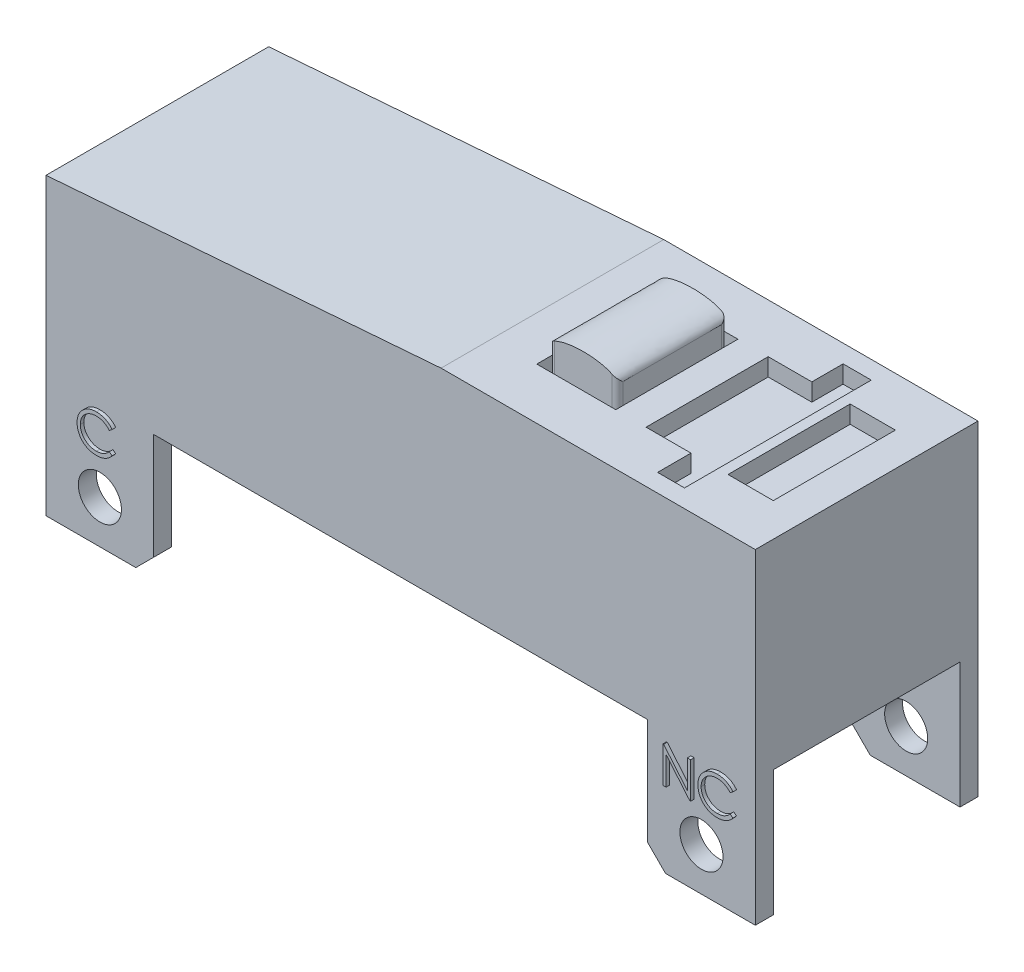
from build123d import *

# Parameters (mm, degrees)
SKETCH3_R               = 0.6
BOSS_EXTRUDE1_DEPTH     = 6.2
SHELL1_T                = -0.5
SKETCH5_W               = 5.2
SKETCH5_H               = 3.5
CUT_EXTRUDE1_DEPTH      = 1
CUT_EXTRUDE1_DEPTH_BACK = 20.75
SKETCH6_W               = 1.26
SKETCH6_H               = 3.4
CUT_EXTRUDE2_DEPTH      = 0.49
SKETCH7_W               = 2.2
SKETCH7_H               = 3.4
CUT_EXTRUDE3_DEPTH      = 0.49
BOSS_EXTRUDE2_DEPTH     = 1.24
CUT_EXTRUDE4_DEPTH      = 2.63
CUT_EXTRUDE4_DEPTH_BACK = 5.57
BOSS_EXTRUDE3_DEPTH     = 0.1


with BuildPart() as part:
    # Sketch3 → Boss-Extrude1 (new body)
    with BuildSketch(Plane.XY):
        Polygon((11.659703504, 6.419407008), (5.659703504, 6.419407008), (2.909703504, 6.419407008), (-8.090296496, 5.569407008), (-8.090296496, -2.640592992), (-5.590296496, -2.640592992), (-5.090296496, -2.140592992), (-5.090296496, 0.819407008), (8.659703504, 0.819407008), (8.659703504, -2.140592992), (9.159703504, -2.640592992), (11.659703504, -2.640592992), align=None)
        with Locations((-6.590296496, -1.440592992)):
            Circle(SKETCH3_R, mode=Mode.SUBTRACT)
        with Locations((10.159703504, -1.440592992)):
            Circle(SKETCH3_R, mode=Mode.SUBTRACT)
    extrude(amount=BOSS_EXTRUDE1_DEPTH)

    # Shell1
    shell1_openings = [part.faces().sort_by_distance(p)[0] for p in [
        (10.409703504, -2.640592992, 3.1),
        (8.659703504, -0.660592992, 3.1),
        (1.784703504, 0.819407008, 3.1),
        (-5.090296496, -0.660592992, 3.1),
        (-6.840296496, -2.640592992, 3.1),
    ]]
    offset(amount=SHELL1_T, openings=shell1_openings)

    # Sketch5 → Cut-Extrude1 (cut, two sides)
    with BuildSketch(Plane(origin=(11.659703504, 0, 0), x_dir=(0, 0, -1), z_dir=(1, 0, 0))) as cut_extrude1_sk:
        with Locations((-3.1, -0.890592992)):
            Rectangle(SKETCH5_W, SKETCH5_H)
    extrude(amount=CUT_EXTRUDE1_DEPTH, mode=Mode.SUBTRACT)
    extrude(cut_extrude1_sk.sketch, amount=-CUT_EXTRUDE1_DEPTH_BACK, mode=Mode.SUBTRACT)

    # Sketch6 → Cut-Extrude2 (cut)
    with BuildSketch(Plane(origin=(0, 6.419407008, 0), x_dir=(1, 0, 0), z_dir=(0, 1, 0))):
        with Locations((10.099703504, -3.07)):
            Rectangle(SKETCH6_W, SKETCH6_H)
    extrude(amount=-CUT_EXTRUDE2_DEPTH, mode=Mode.SUBTRACT)

    # Sketch7 → Cut-Extrude3 (cut)
    with BuildSketch(Plane(origin=(0, 6.419407008, 0), x_dir=(1, 0, 0), z_dir=(0, 1, 0))):
        Polygon((9.18784127, -0.5), (9.18784127, -5.7), (8.43784127, -5.7), (8.43784127, -4.77), (7.18784127, -4.77), (7.18784127, -1.37), (8.403045117, -1.37), (8.403045117, -0.5), align=None)
        with Locations((5.244810149, -3.07)):
            Rectangle(SKETCH7_W, SKETCH7_H)
    extrude(amount=-CUT_EXTRUDE3_DEPTH, mode=Mode.SUBTRACT)

    # Sketch8 → Boss-Extrude2 (add)
    with BuildSketch(Plane(origin=(0, 5.929407008, 0), x_dir=(1, 0, 0), z_dir=(0, 1, 0))):
        with BuildLine():
            Line((4.444810149, -1.52), (6.044810149, -1.52))
            ThreePointArc((6.044810149, -1.52), (6.150876166, -1.563933983), (6.194810149, -1.67))
            Line((6.194810149, -1.67), (6.194810149, -4.42))
            ThreePointArc((6.194810149, -4.42), (6.150876166, -4.526066017), (6.044810149, -4.57))
            Line((6.044810149, -4.57), (4.444810149, -4.57))
            ThreePointArc((4.444810149, -4.57), (4.338744132, -4.526066017), (4.294810149, -4.42))
            Line((4.294810149, -4.42), (4.294810149, -1.67))
            ThreePointArc((4.294810149, -1.67), (4.338744132, -1.563933983), (4.444810149, -1.52))
        make_face()
    extrude(amount=BOSS_EXTRUDE2_DEPTH)

    # Sketch9 → Cut-Extrude4 (cut, two sides)
    with BuildSketch(Plane.XY.offset(4.57)) as cut_extrude4_sk:
        with BuildLine():
            Line((4.294810149, 7.169407008), (4.294810149, 6.847617942))
            add(Edge.make_bspline(
                [(4.444810149, 7.021163032), (4.294810149, 6.941828134), (4.294810149, 6.847617942)],
                knots=[5.703153856, 5.703153856, 5.703153856, 6.283185307, 6.283185307, 6.283185307], degree=2, weights=[0.863566286, 0.891846399, 1]))
            Line((4.444810149, 7.021163032), (4.444810149, 7.169407008))
            Line((4.444810149, 7.169407008), (4.294810149, 7.169407008))
        make_face()
        with BuildLine():
            Line((4.444810149, 7.169407008), (4.444810149, 7.021163032))
            add(Edge.make_bspline(
                [(5.244810149, 7.169407008), (4.725097851, 7.169407008), (4.444810149, 7.021163032)],
                knots=[4.71238898, 4.71238898, 4.71238898, 5.703153856, 5.703153856, 5.703153856], degree=2, weights=[1, 0.815260382, 0.863566286]))
            Line((5.244810172, 7.169407008), (4.444810149, 7.169407008))
        make_face()
        with BuildLine():
            Line((6.044810149, 7.169407008), (5.244810172, 7.169407008))
            add(Edge.make_bspline(
                [(6.044810149, 7.021163032), (5.764522447, 7.169407008), (5.244810149, 7.169407008)],
                knots=[3.721624105, 3.721624105, 3.721624105, 4.71238898, 4.71238898, 4.71238898], degree=2, weights=[0.863566286, 0.815260382, 1]))
            Line((6.044810149, 7.021163032), (6.044810149, 7.169407008))
        make_face()
        with BuildLine():
            Line((6.194810149, 7.169407008), (6.044810149, 7.169407008))
            Line((6.044810149, 7.169407008), (6.044810149, 7.021163032))
            add(Edge.make_bspline(
                [(6.194810149, 6.847617942), (6.194810149, 6.941828134), (6.044810149, 7.021163032)],
                knots=[3.141592654, 3.141592654, 3.141592654, 3.721624105, 3.721624105, 3.721624105], degree=2, weights=[1, 0.891846399, 0.863566286]))
            Line((6.194810149, 6.847617942), (6.194810149, 7.169407008))
        make_face()
    extrude(amount=CUT_EXTRUDE4_DEPTH, mode=Mode.SUBTRACT)
    extrude(cut_extrude4_sk.sketch, amount=-CUT_EXTRUDE4_DEPTH_BACK, mode=Mode.SUBTRACT)

    # Sketch11 → Boss-Extrude3 (add)
    with BuildSketch(Plane.XY.offset(6.2)):
        Polygon((9.18687242, -0.45139452), (9.18687242, 0.54860548), (9.205702548, 0.54860548), (9.8663596, -0.238453815), (9.8663596, 0.54860548), (9.956103189, 0.54860548), (9.956103189, -0.45139452), (9.935670497, -0.45139452), (9.27661601, 0.333861891), (9.27661601, -0.45139452), align=None)
        with BuildLine():
            Line((11.135590369, 0.365111891), (11.057064728, 0.305015737))
            add(Edge.make_bspline(
                [(11.057064728, 0.305015737), (11.051463045, 0.311691728), (11.040335203, 0.324953704), (11.022432574, 0.343576431), (11.003774962, 0.361023649), (10.984369499, 0.377378471), (10.963866893, 0.392068976), (10.942763808, 0.40586072), (10.920707223, 0.41822293), (10.890206728, 0.433212355), (10.850307343, 0.448854114), (10.800080246, 0.461969323), (10.747648503, 0.47031823), (10.711877761, 0.47122247), (10.693683317, 0.471682403)],
                knots=[0, 0, 0, 0, 2.6139e-05, 5.1925e-05, 7.7436e-05, 0.000102751, 0.000127994, 0.000153053, 0.000178348, 0.000203791, 0.000254978, 0.00030658, 0.000359276, 0.000413825, 0.000413825, 0.000413825, 0.000413825], degree=3))
            add(Edge.make_bspline(
                [(10.693683317, 0.471682403), (10.683659518, 0.471566986), (10.663704948, 0.471337221), (10.634091099, 0.468306042), (10.605030227, 0.464045697), (10.576541237, 0.457724176), (10.548660391, 0.449731999), (10.521205419, 0.440181881), (10.494573819, 0.428366212), (10.46839718, 0.415306709), (10.443317405, 0.400556011), (10.419587392, 0.384466482), (10.397293687, 0.367218168), (10.376418655, 0.348746424), (10.356940955, 0.329134435), (10.339001723, 0.308173195), (10.322663035, 0.285929716), (10.307601028, 0.262697314), (10.294111675, 0.238543659), (10.282817424, 0.213379354), (10.27281596, 0.187635324), (10.264901891, 0.161020707), (10.258637743, 0.133722774), (10.254315554, 0.105668263), (10.251318848, 0.076915783), (10.251090226, 0.057427408), (10.250974984, 0.047603878)],
                knots=[0, 0, 0, 0, 3.0059e-05, 5.9839e-05, 8.9217e-05, 0.000118137, 0.000147304, 0.000176195, 0.000205261, 0.000234645, 0.000263917, 0.000292475, 0.000320603, 0.000348418, 0.00037604, 0.00040346, 0.000431105, 0.000458776, 0.000486483, 0.000514004, 0.000541459, 0.000569281, 0.000597223, 0.000625414, 0.000654396, 0.000683854, 0.000683854, 0.000683854, 0.000683854], degree=3))
            add(Edge.make_bspline(
                [(10.250974984, 0.047603878), (10.251335504, 0.032823501), (10.252043337, 0.003804191), (10.258342861, -0.038701698), (10.267915744, -0.079421891), (10.282263051, -0.118101845), (10.299954209, -0.155218519), (10.322308669, -0.190143906), (10.348199108, -0.223405781), (10.3779918, -0.254218052), (10.410679176, -0.282364831), (10.445750008, -0.307150711), (10.483116947, -0.327812106), (10.522367413, -0.345005234), (10.563803445, -0.358221442), (10.607350532, -0.367525477), (10.652913959, -0.373594672), (10.684048073, -0.374175725), (10.699893253, -0.374471443)],
                knots=[0, 0, 0, 0, 4.4316e-05, 8.7009e-05, 0.000128647, 0.000169585, 0.000210529, 0.000251766, 0.000293722, 0.000336791, 0.000380117, 0.000422965, 0.000465381, 0.000507994, 0.000551326, 0.000595608, 0.00064145, 0.00068896, 0.00068896, 0.00068896, 0.00068896], degree=3))
            add(Edge.make_bspline(
                [(10.699893253, -0.374471443), (10.717351165, -0.373988934), (10.75171251, -0.373039242), (10.802103375, -0.364993742), (10.850342165, -0.351948623), (10.896431475, -0.333692074), (10.940241374, -0.309959134), (10.98184042, -0.281188312), (11.021263726, -0.247105931), (11.044969806, -0.22108218), (11.057064728, -0.207804776)],
                knots=[0, 0, 0, 0, 5.2348e-05, 0.000103034, 0.00015265, 0.000202013, 0.000251398, 0.000301797, 0.000353488, 0.000407333, 0.000407333, 0.000407333, 0.000407333], degree=3))
            Line((11.057064728, -0.207804776), (11.135590369, -0.267299968))
            add(Edge.make_bspline(
                [(11.135590369, -0.267299968), (11.129270909, -0.275453812), (11.116662259, -0.291722442), (11.096245682, -0.314657216), (11.074737883, -0.336229798), (11.051979109, -0.356266261), (11.028231168, -0.375167537), (11.003067651, -0.392396632), (10.976819356, -0.408194027), (10.949575219, -0.422658863), (10.921364187, -0.435492362), (10.892220062, -0.446479153), (10.862268469, -0.455943407), (10.831508038, -0.463729674), (10.799874965, -0.469807127), (10.767483401, -0.473869891), (10.734263437, -0.476653295), (10.711851602, -0.476906986), (10.700494215, -0.477035545)],
                knots=[0, 0, 0, 0, 3.0941e-05, 6.1734e-05, 9.2046e-05, 0.000122273, 0.000152652, 0.000183046, 0.00021369, 0.000244516, 0.000275535, 0.0003066, 0.000337898, 0.000369721, 0.000401741, 0.000434464, 0.000467619, 0.000501683, 0.000501683, 0.000501683, 0.000501683], degree=3))
            add(Edge.make_bspline(
                [(10.700494215, -0.477035545), (10.689738881, -0.47696069), (10.668471541, -0.476812674), (10.637071898, -0.474414912), (10.606503446, -0.471143558), (10.576853553, -0.466217806), (10.547960418, -0.460405138), (10.520085965, -0.45261335), (10.492955905, -0.443885017), (10.466679236, -0.433626449), (10.441233608, -0.422050397), (10.41670109, -0.408967095), (10.393092966, -0.394486562), (10.370177132, -0.378927987), (10.348292108, -0.361791616), (10.327248244, -0.343315434), (10.306927536, -0.323561717), (10.29435534, -0.309317473), (10.288034279, -0.302155738)],
                knots=[0, 0, 0, 0, 3.2257e-05, 6.3785e-05, 9.4423e-05, 0.000124458, 0.000153923, 0.00018279, 0.000211233, 0.000239394, 0.000267362, 0.000295053, 0.000322744, 0.000350414, 0.000378103, 0.000406069, 0.0004344, 0.000463048, 0.000463048, 0.000463048, 0.000463048], degree=3))
            add(Edge.make_bspline(
                [(10.288034279, -0.302155738), (10.277909809, -0.289715398), (10.257783102, -0.264984909), (10.232032906, -0.2249032), (10.209990748, -0.183055141), (10.192169056, -0.139220875), (10.178236847, -0.093498765), (10.168585077, -0.04586576), (10.16231319, 0.003633652), (10.161595964, 0.037301305), (10.161231394, 0.054414775)],
                knots=[0, 0, 0, 0, 4.8087e-05, 9.5594e-05, 0.000142635, 0.000189804, 0.000237331, 0.000285811, 0.000335455, 0.000386777, 0.000386777, 0.000386777, 0.000386777], degree=3))
            add(Edge.make_bspline(
                [(10.161231394, 0.054414775), (10.161675735, 0.072402048), (10.162549949, 0.107790883), (10.169977319, 0.159726298), (10.181925546, 0.209483841), (10.198896086, 0.256970625), (10.220411901, 0.30243642), (10.246990933, 0.345533907), (10.278324402, 0.386538707), (10.314166564, 0.424828635), (10.353471517, 0.459839879), (10.395562607, 0.490641652), (10.440357449, 0.516275228), (10.48736255, 0.537702703), (10.536929887, 0.554172549), (10.588953707, 0.565702031), (10.643336254, 0.57287835), (10.680439804, 0.573785552), (10.699292292, 0.574246506)],
                knots=[0, 0, 0, 0, 5.394e-05, 0.000106123, 0.000157041, 0.000207222, 0.000257131, 0.00030767, 0.000358834, 0.0004117, 0.000464768, 0.000516537, 0.00056787, 0.00061933, 0.000671275, 0.000724248, 0.000778985, 0.000835527, 0.000835527, 0.000835527, 0.000835527], degree=3))
            add(Edge.make_bspline(
                [(10.699292292, 0.574246506), (10.710782141, 0.574108752), (10.73352514, 0.573836083), (10.767168755, 0.571177185), (10.799923706, 0.566744726), (10.831812558, 0.560711563), (10.862990448, 0.553223757), (10.893219088, 0.543469386), (10.922675856, 0.532316091), (10.951174973, 0.519470815), (10.978579701, 0.505051746), (11.004881507, 0.489218711), (11.029871466, 0.471991338), (11.053725423, 0.453516145), (11.07604434, 0.433402271), (11.097461906, 0.412202958), (11.117250785, 0.38930758), (11.129465984, 0.373191884), (11.135590369, 0.365111891)],
                knots=[0, 0, 0, 0, 3.4464e-05, 6.8219e-05, 0.000101167, 0.00013358, 0.000165549, 0.000197289, 0.000228801, 0.000260002, 0.000291005, 0.000321649, 0.000352043, 0.000382017, 0.000412094, 0.000442123, 0.000472369, 0.000502782, 0.000502782, 0.000502782, 0.000502782], degree=3))
        make_face()
        with BuildLine():
            Line((-6.15051233, 0.457442588), (-6.229037971, 0.397346434))
            add(Edge.make_bspline(
                [(-6.229037971, 0.397346434), (-6.234639654, 0.404022425), (-6.245767496, 0.417284401), (-6.263670125, 0.435907128), (-6.282327737, 0.453354346), (-6.3017332, 0.469709169), (-6.322235806, 0.484399673), (-6.343338891, 0.498191417), (-6.365395476, 0.510553628), (-6.395895971, 0.525543052), (-6.435795356, 0.541184811), (-6.486022453, 0.55430002), (-6.538454196, 0.562648927), (-6.574224938, 0.563553167), (-6.592419382, 0.564013101)],
                knots=[0, 0, 0, 0, 2.6139e-05, 5.1925e-05, 7.7436e-05, 0.000102751, 0.000127994, 0.000153053, 0.000178348, 0.000203791, 0.000254978, 0.00030658, 0.000359276, 0.000413825, 0.000413825, 0.000413825, 0.000413825], degree=3))
            add(Edge.make_bspline(
                [(-6.592419382, 0.564013101), (-6.602443181, 0.563897683), (-6.622397751, 0.563667918), (-6.6520116, 0.56063674), (-6.681072472, 0.556376394), (-6.709561462, 0.550054873), (-6.737442308, 0.542062696), (-6.76489728, 0.532512578), (-6.79152888, 0.520696909), (-6.817705519, 0.507637406), (-6.842785294, 0.492886708), (-6.866515307, 0.476797179), (-6.888809012, 0.459548866), (-6.909684044, 0.441077121), (-6.929161744, 0.421465132), (-6.947100976, 0.400503892), (-6.963439664, 0.378260414), (-6.978501671, 0.355028011), (-6.991991024, 0.330874357), (-7.003285275, 0.305710051), (-7.013286739, 0.279966021), (-7.021200808, 0.253351404), (-7.027464956, 0.226053471), (-7.031787145, 0.19799896), (-7.034783851, 0.16924648), (-7.035012473, 0.149758105), (-7.035127715, 0.139934575)],
                knots=[0, 0, 0, 0, 3.0059e-05, 5.9839e-05, 8.9217e-05, 0.000118137, 0.000147304, 0.000176195, 0.000205261, 0.000234645, 0.000263917, 0.000292475, 0.000320603, 0.000348418, 0.00037604, 0.00040346, 0.000431105, 0.000458776, 0.000486483, 0.000514004, 0.000541459, 0.000569281, 0.000597223, 0.000625414, 0.000654396, 0.000683854, 0.000683854, 0.000683854, 0.000683854], degree=3))
            add(Edge.make_bspline(
                [(-7.035127715, 0.139934575), (-7.034767195, 0.125154198), (-7.034059362, 0.096134888), (-7.027759838, 0.053628999), (-7.018186955, 0.012908807), (-7.003839648, -0.025771148), (-6.98614849, -0.062887822), (-6.96379403, -0.097813209), (-6.937903591, -0.131075084), (-6.908110899, -0.161887355), (-6.875423523, -0.190034134), (-6.840352691, -0.214820014), (-6.802985752, -0.235481409), (-6.763735286, -0.252674537), (-6.722299254, -0.265890745), (-6.678752167, -0.27519478), (-6.63318874, -0.281263974), (-6.602054626, -0.281845028), (-6.586209446, -0.282140746)],
                knots=[0, 0, 0, 0, 4.4316e-05, 8.7009e-05, 0.000128647, 0.000169585, 0.000210529, 0.000251766, 0.000293722, 0.000336791, 0.000380117, 0.000422965, 0.000465381, 0.000507994, 0.000551326, 0.000595608, 0.00064145, 0.00068896, 0.00068896, 0.00068896, 0.00068896], degree=3))
            add(Edge.make_bspline(
                [(-6.586209446, -0.282140746), (-6.568751534, -0.281658237), (-6.534390189, -0.280708545), (-6.483999324, -0.272663045), (-6.435760534, -0.259617926), (-6.389671224, -0.241361376), (-6.345861325, -0.217628437), (-6.304262279, -0.188857615), (-6.264838973, -0.154775234), (-6.241132893, -0.128751483), (-6.229037971, -0.115474079)],
                knots=[0, 0, 0, 0, 5.2348e-05, 0.000103034, 0.00015265, 0.000202013, 0.000251398, 0.000301797, 0.000353488, 0.000407333, 0.000407333, 0.000407333, 0.000407333], degree=3))
            Line((-6.229037971, -0.115474079), (-6.15051233, -0.174969271))
            add(Edge.make_bspline(
                [(-6.15051233, -0.174969271), (-6.15683179, -0.183123115), (-6.16944044, -0.199391745), (-6.189857017, -0.222326519), (-6.211364816, -0.243899101), (-6.23412359, -0.263935564), (-6.257871531, -0.28283684), (-6.283035048, -0.300065934), (-6.309283343, -0.31586333), (-6.33652748, -0.330328166), (-6.364738512, -0.343161665), (-6.393882637, -0.354148455), (-6.42383423, -0.36361271), (-6.454594661, -0.371398977), (-6.486227734, -0.37747643), (-6.518619298, -0.381539194), (-6.551839262, -0.384322598), (-6.574251097, -0.384576288), (-6.585608484, -0.384704848)],
                knots=[0, 0, 0, 0, 3.0941e-05, 6.1734e-05, 9.2046e-05, 0.000122273, 0.000152652, 0.000183046, 0.00021369, 0.000244516, 0.000275535, 0.0003066, 0.000337898, 0.000369721, 0.000401741, 0.000434464, 0.000467619, 0.000501683, 0.000501683, 0.000501683, 0.000501683], degree=3))
            add(Edge.make_bspline(
                [(-6.585608484, -0.384704848), (-6.596363818, -0.384629993), (-6.617631158, -0.384481977), (-6.649030801, -0.382084214), (-6.679599253, -0.378812861), (-6.709249146, -0.373887109), (-6.738142281, -0.368074441), (-6.766016734, -0.360282653), (-6.793146794, -0.35155432), (-6.819423463, -0.341295752), (-6.844869091, -0.3297197), (-6.869401609, -0.316636397), (-6.893009733, -0.302155865), (-6.915925567, -0.28659729), (-6.937810591, -0.269460918), (-6.958854455, -0.250984737), (-6.979175163, -0.23123102), (-6.991747359, -0.216986776), (-6.99806842, -0.20982504)],
                knots=[0, 0, 0, 0, 3.2257e-05, 6.3785e-05, 9.4423e-05, 0.000124458, 0.000153923, 0.00018279, 0.000211233, 0.000239394, 0.000267362, 0.000295053, 0.000322744, 0.000350414, 0.000378103, 0.000406069, 0.0004344, 0.000463048, 0.000463048, 0.000463048, 0.000463048], degree=3))
            add(Edge.make_bspline(
                [(-6.99806842, -0.20982504), (-7.00819289, -0.197384701), (-7.028319597, -0.172654212), (-7.054069793, -0.132572503), (-7.076111951, -0.090724443), (-7.093933643, -0.046890178), (-7.107865852, -0.001168067), (-7.117517622, 0.046464937), (-7.123789509, 0.095964349), (-7.124506735, 0.129632003), (-7.124871305, 0.146745472)],
                knots=[0, 0, 0, 0, 4.8087e-05, 9.5594e-05, 0.000142635, 0.000189804, 0.000237331, 0.000285811, 0.000335455, 0.000386777, 0.000386777, 0.000386777, 0.000386777], degree=3))
            add(Edge.make_bspline(
                [(-7.124871305, 0.146745472), (-7.124426964, 0.164732745), (-7.12355275, 0.20012158), (-7.11612538, 0.252056996), (-7.104177153, 0.301814538), (-7.087206613, 0.349301322), (-7.065690798, 0.394767117), (-7.039111766, 0.437864604), (-7.007778297, 0.478869404), (-6.971936135, 0.517159333), (-6.932631182, 0.552170576), (-6.890540092, 0.582972349), (-6.84574525, 0.608605925), (-6.798740149, 0.6300334), (-6.749172812, 0.646503246), (-6.697148992, 0.658032728), (-6.642766445, 0.665209047), (-6.605662895, 0.666116249), (-6.586810407, 0.666577203)],
                knots=[0, 0, 0, 0, 5.394e-05, 0.000106123, 0.000157041, 0.000207222, 0.000257131, 0.00030767, 0.000358834, 0.0004117, 0.000464768, 0.000516537, 0.00056787, 0.00061933, 0.000671275, 0.000724248, 0.000778985, 0.000835527, 0.000835527, 0.000835527, 0.000835527], degree=3))
            add(Edge.make_bspline(
                [(-6.586810407, 0.666577203), (-6.575320558, 0.666439449), (-6.552577559, 0.66616678), (-6.518933944, 0.663507882), (-6.486178993, 0.659075423), (-6.454290141, 0.65304226), (-6.423112251, 0.645554454), (-6.392883611, 0.635800083), (-6.363426843, 0.624646789), (-6.334927726, 0.611801513), (-6.307522998, 0.597382444), (-6.281221192, 0.581549408), (-6.256231233, 0.564322035), (-6.232377276, 0.545846842), (-6.210058359, 0.525732968), (-6.188640793, 0.504533655), (-6.168851914, 0.481638277), (-6.156636715, 0.465522581), (-6.15051233, 0.457442588)],
                knots=[0, 0, 0, 0, 3.4464e-05, 6.8219e-05, 0.000101167, 0.00013358, 0.000165549, 0.000197289, 0.000228801, 0.000260002, 0.000291005, 0.000321649, 0.000352043, 0.000382017, 0.000412094, 0.000442123, 0.000472369, 0.000502782, 0.000502782, 0.000502782, 0.000502782], degree=3))
        make_face()
    extrude(amount=BOSS_EXTRUDE3_DEPTH)


solid = part.part
